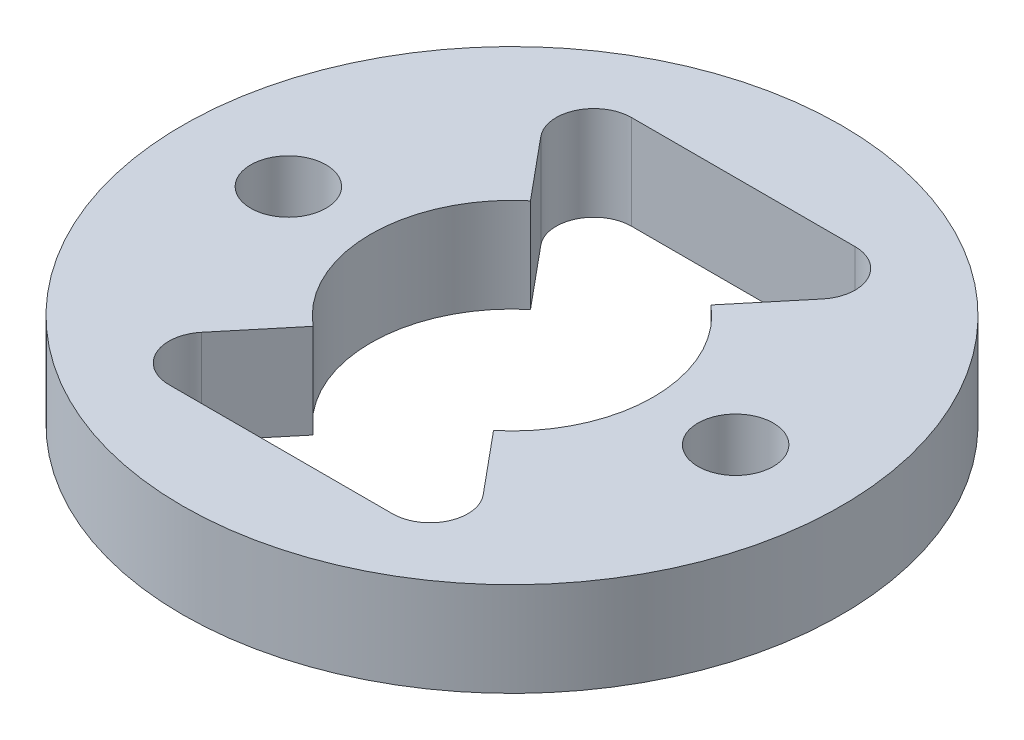
from build123d import *

# Parameters (mm, degrees)
SKETCH1_R           = 14
SKETCH1_R_2         = 6
SKETCH1_R_3         = 1.6
BOSS_EXTRUDE1_DEPTH = 4
CUT_EXTRUDE1_REACH  = 6


with BuildPart() as part:
    # Sketch1 → Boss-Extrude1 (new body)
    with BuildSketch(Plane.XZ.offset(-7.168741666)):
        with Locations((7.114749013, 17.625339305)):
            Circle(SKETCH1_R)
        with Locations((7.114749013, 17.625339305)):
            Circle(SKETCH1_R_2, mode=Mode.SUBTRACT)
        with Locations((2.364749013, 25.852580641)):
            Circle(SKETCH1_R_3, mode=Mode.SUBTRACT)
        with Locations((-2.385250987, 17.625339305)):
            Circle(SKETCH1_R_3, mode=Mode.SUBTRACT)
        with Locations((2.364749013, 9.398097969)):
            Circle(SKETCH1_R_3, mode=Mode.SUBTRACT)
        with Locations((11.864749013, 9.398097969)):
            Circle(SKETCH1_R_3, mode=Mode.SUBTRACT)
        with Locations((16.614749013, 17.625339305)):
            Circle(SKETCH1_R_3, mode=Mode.SUBTRACT)
        with Locations((11.864749013, 25.852580641)):
            Circle(SKETCH1_R_3, mode=Mode.SUBTRACT)
    extrude(amount=BOSS_EXTRUDE1_DEPTH)

    # Sketch2 → Cut-Extrude1 (cut, up to next)
    with BuildSketch(Plane.XZ.offset(-3.168741666), mode=Mode.PRIVATE) as cut_extrude1_sk1:
        Polygon((11.864749013, 7.798097969), (2.364749013, 7.798097969), (1.133638883, 10.420041142), (3.282462114, 13.008676319), (10.947035911, 13.008676319), (13.095859142, 10.420041142), align=None)
    cut_extrude1_tool1 = extrude(cut_extrude1_sk1.sketch, amount=-CUT_EXTRUDE1_REACH, mode=Mode.PRIVATE) & part.part
    add(cut_extrude1_tool1.solids().sort_by_distance((7.114749, 3.168742, 10.326739))[0], mode=Mode.SUBTRACT)
    # Sketch2 → Cut-Extrude1 (cut, up to next)
    with BuildSketch(Plane.XZ.offset(-3.168741666), mode=Mode.PRIVATE) as cut_extrude1_sk2:
        Polygon((1.133638883, 24.830637468), (2.364749013, 27.452580641), (11.864749013, 27.452580641), (13.095859142, 24.830637468), (10.947035911, 22.242002291), (3.282462114, 22.242002291), align=None)
    cut_extrude1_tool2 = extrude(cut_extrude1_sk2.sketch, amount=-CUT_EXTRUDE1_REACH, mode=Mode.PRIVATE) & part.part
    add(cut_extrude1_tool2.solids().sort_by_distance((7.114749, 3.168742, 24.923939))[0], mode=Mode.SUBTRACT)


solid = part.part
